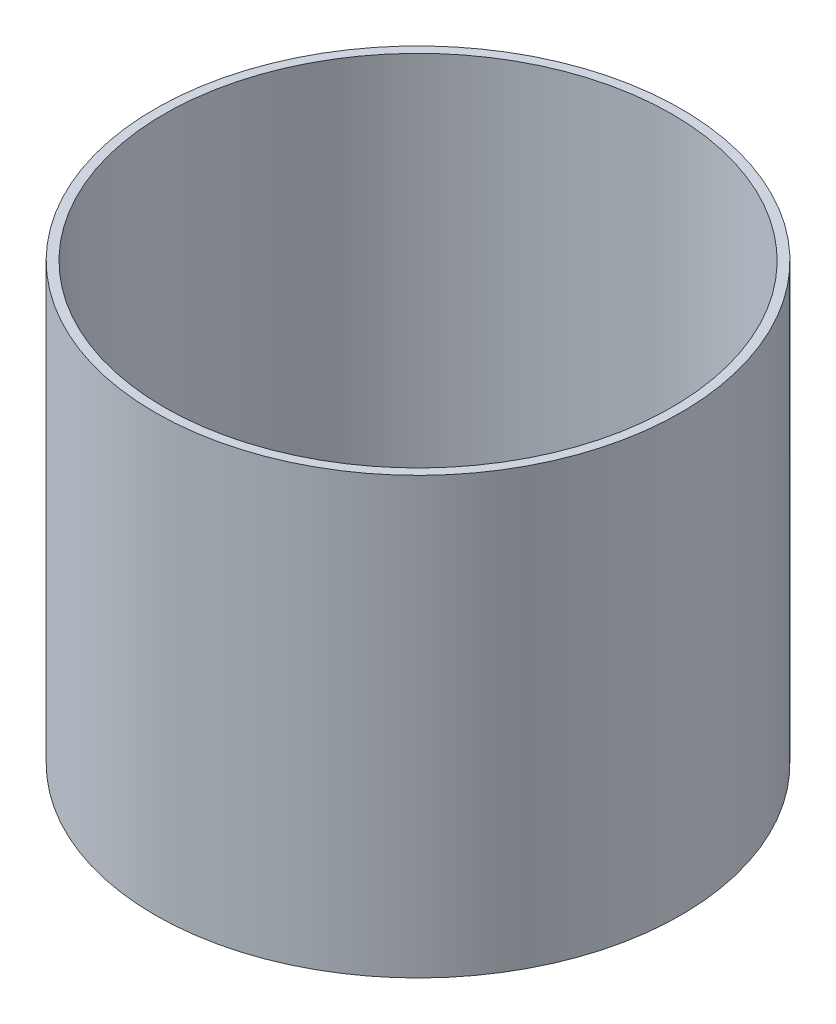
from build123d import *

# Parameters (mm, degrees)
SKETCH1_R           = 92.075
SKETCH1_R_2         = 88.9
BOSS_EXTRUDE1_DEPTH = 152.4


with BuildPart() as part:
    # Sketch1 → Boss-Extrude1 (new body)
    with BuildSketch(Plane(origin=(0, 0, 0), x_dir=(1, 0, 0), z_dir=(0, 1, 0))):
        Circle(SKETCH1_R)
        Circle(SKETCH1_R_2, mode=Mode.SUBTRACT)
    extrude(amount=BOSS_EXTRUDE1_DEPTH)


solid = part.part
